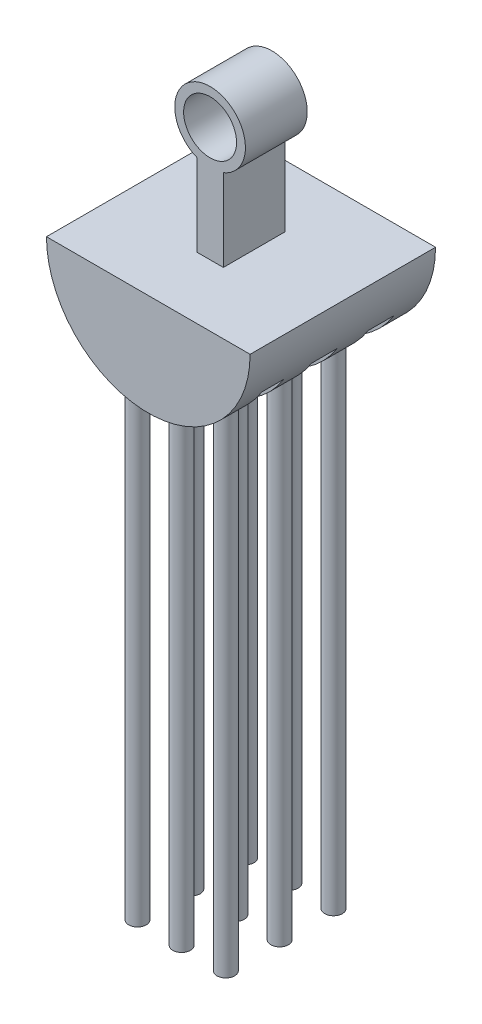
from build123d import *

# Parameters (mm, degrees)
SKETCH2_R                = 4
SKETCH2_R_2              = 3
BOSS_EXTRUDE1_DEPTH      = 7
BOSS_EXTRUDE2_DEPTH      = 7
BOSS_EXTRUDE3_DEPTH      = 7
BOSS_EXTRUDE3_DEPTH_BACK = 14
CUT_EXTRUDE2_DEPTH       = 169
CUT_EXTRUDE2_DEPTH_BACK  = 169
SKETCH5_W                = 2.481427535
SKETCH5_H                = 11.249138159
SKETCH5_W_2              = 2.867427374
SKETCH5_W_3              = 2.922570208
SKETCH6_R                = 1
BOSS_EXTRUDE5_DEPTH      = 60


with BuildPart() as part:
    # Sketch2 → Boss-Extrude1 (new body)
    with BuildSketch(Plane.XY):
        Circle(SKETCH2_R)
        Circle(SKETCH2_R_2, mode=Mode.SUBTRACT)
    extrude(amount=BOSS_EXTRUDE1_DEPTH)

    # Sketch3 → Boss-Extrude2 (add)
    with BuildSketch(Plane.XY.offset(7)):
        Polygon((0, -3), (-1.5, -3), (-1.5, -13), (1.5, -13), (1.5, -3), align=None)
    extrude(amount=-BOSS_EXTRUDE2_DEPTH)

    # Sketch4 → Boss-Extrude3 (add, two sides: drawn at the far end of the back side and taken through both)
    with BuildSketch(Plane.XY.offset(7).offset(-BOSS_EXTRUDE3_DEPTH_BACK)):
        with BuildLine():
            Line((1.5, -13), (11.531332628, -13))
            ThreePointArc((11.531332628, -13), (0, -24.531332628), (-11.531332628, -13))
            Line((-11.531332628, -13), (-1.5, -13))
            Line((-1.5, -13), (1.5, -13))
        make_face()
    extrude(amount=BOSS_EXTRUDE3_DEPTH + BOSS_EXTRUDE3_DEPTH_BACK)

    # Sketch5 → Cut-Extrude2 (cut, two sides: drawn at the far end of the back side and taken through both)
    with BuildSketch(Plane(origin=(1.5, 0, 0), x_dir=(0, 0, -1), z_dir=(1, 0, 0)).offset(-CUT_EXTRUDE2_DEPTH_BACK)):
        with Locations((-9.661011409, -24.733382447)):
            Rectangle(SKETCH5_W, SKETCH5_H)
        with Locations((-3.84344241, -24.733382447)):
            Rectangle(SKETCH5_W_2, SKETCH5_H)
        with Locations((2.580697764, -24.733382447)):
            Rectangle(SKETCH5_W_3, SKETCH5_H)
    extrude(amount=CUT_EXTRUDE2_DEPTH + CUT_EXTRUDE2_DEPTH_BACK, mode=Mode.SUBTRACT)

    # Sketch6 → Boss-Extrude5 (add)
    with BuildSketch(Plane.XZ.offset(19.108813367)):
        with Locations((-5.486205248, 9.734324146)):
            Circle(SKETCH6_R)
        with Locations((-0.486205248, 9.734324146)):
            Circle(SKETCH6_R)
        with Locations((4.513794752, 9.734324146)):
            Circle(SKETCH6_R)
        with Locations((-0.486205248, 3.634324146)):
            Circle(SKETCH6_R)
        with Locations((4.513794752, 3.634324146)):
            Circle(SKETCH6_R)
        with Locations((-0.486205248, -2.465675854)):
            Circle(SKETCH6_R)
        with Locations((4.513794752, -2.465675854)):
            Circle(SKETCH6_R)
        with Locations((-5.486205248, 3.634324146)):
            Circle(SKETCH6_R)
        with Locations((-5.486205248, -2.465675854)):
            Circle(SKETCH6_R)
    extrude(amount=BOSS_EXTRUDE5_DEPTH)


solid = part.part
